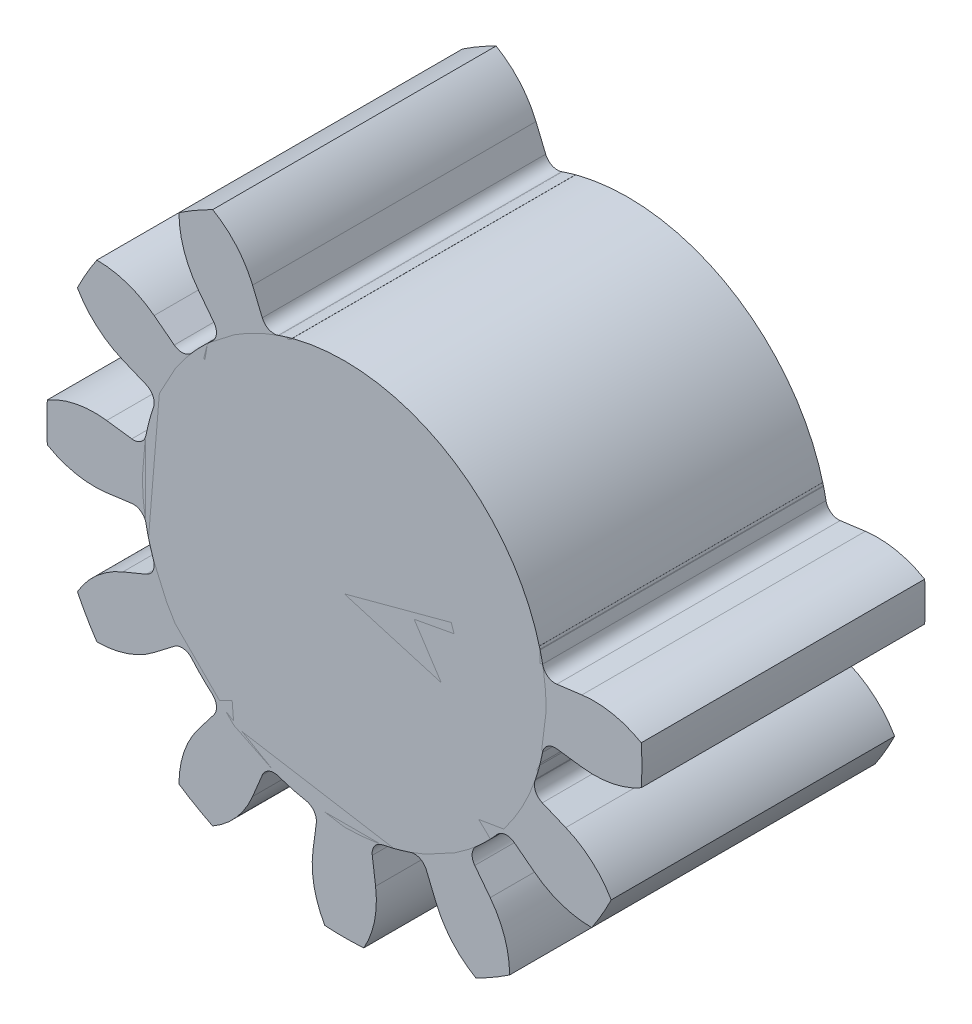
from build123d import *

# Parameters (mm, degrees)
MAINGEAR_DEPTH                     = 10
CONG_1_R                           = 0.45
R_P_TITION_CIRCULAIRE1_COUNT       = 9
R_P_TITION_CIRCULAIRE1_ANGLE       = 240
CONG_1_OF_R_P_TITION_CIRCULAIRE1_R = 0.45
ESQUISSE5_R                        = 7.125
MAINBASECIRCLE_DEPTH               = 10


with BuildPart() as part:
    # Esquisse1 → MainGear (new body)
    with BuildSketch(Plane.XY):
        with BuildLine():
            Line((0, 0), (6.882221512, 1.844085696))
            ThreePointArc((6.882221512, 1.844085696), (6.988095123, 1.390018544), (7.064044637, 0.92999912))
            Line((7.064044637, 0.92999912), (8.384880781, 1.103890497))
            ThreePointArc((8.384880781, 1.103890497), (9.465680859, 1.068283463), (10.477518694, 0.686732857))
            ThreePointArc((10.477518694, 0.686732857), (10.5, 0), (10.477518694, -0.686732857))
            ThreePointArc((10.477518694, -0.686732857), (9.465680859, -1.068283463), (8.384880781, -1.103890497))
            Line((8.384880781, -1.103890497), (7.064044637, -0.92999912))
            ThreePointArc((7.064044637, -0.92999912), (6.988095123, -1.390018544), (6.882221512, -1.844085696))
            Line((6.882221512, -1.844085696), (0, 0))
        make_face()
    maingear = extrude(amount=MAINGEAR_DEPTH)

    # Congé1
    cong_1_edges = [part.edges().sort_by_distance(p)[0] for p in [
        (7.064044637, 0.92999912, 5),
        (7.064044637, -0.92999912, 5),
    ]]
    fillet(cong_1_edges, radius=CONG_1_R)

    # Répétition circulaire1: MainGear ×9 about axis
    r_p_tition_circulaire1_axis = Axis((0, 0, 0), (0, 0, -1))
    for i in range(1, R_P_TITION_CIRCULAIRE1_COUNT):
        add(maingear.rotate(r_p_tition_circulaire1_axis, i * R_P_TITION_CIRCULAIRE1_ANGLE / (R_P_TITION_CIRCULAIRE1_COUNT - 1)))

    # Congé1 of Répétition circulaire1
    cong_1_of_r_p_tition_circulaire1_edges = [part.edges().sort_by_distance(p)[0] for p in [
        (6.582641669, -2.726619456, 5),
        (5.65264255, -4.337425182, 5),
        (4.337425182, -5.65264255, 5),
        (2.726619456, -6.582641669, 5),
        (0.92999912, -7.064044637, 5),
        (-0.92999912, -7.064044637, 5),
        (-2.726619456, -6.582641669, 5),
        (-4.337425182, -5.65264255, 5),
        (-5.65264255, -4.337425182, 5),
        (-6.582641669, -2.726619456, 5),
        (-7.064044637, -0.92999912, 5),
        (-7.064044637, 0.92999912, 5),
        (-6.582641669, 2.726619456, 5),
        (-5.65264255, 4.337425182, 5),
        (-4.337425182, 5.65264255, 5),
        (-2.726619456, 6.582641669, 5),
    ]]
    fillet(cong_1_of_r_p_tition_circulaire1_edges, radius=CONG_1_OF_R_P_TITION_CIRCULAIRE1_R)


with BuildPart() as body_2:
    # Esquisse5 → MainBaseCircle (new body, through all)
    with BuildSketch(Plane.XY.offset(10)):
        Circle(ESQUISSE5_R)
    extrude(amount=-MAINBASECIRCLE_DEPTH)


solid = Compound([part.part, body_2.part])
